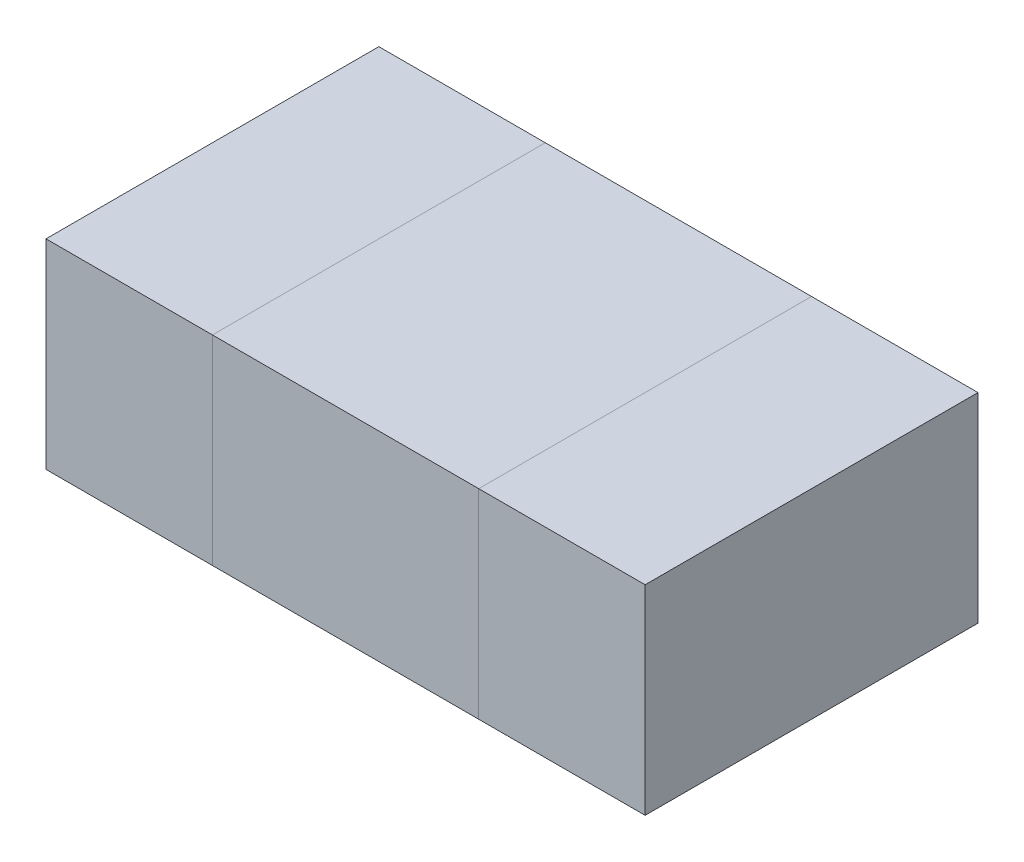
from build123d import *

# Parameters (mm, degrees)
SKETCH1_W             = 0.4
SKETCH1_H             = 0.5
BOSS_EXTRUDE1_DEPTH   = 0.3
SKETCH2_W             = 0.25
SKETCH2_H             = 0.5
BOSS_EXTRUDE2_DEPTH   = 0.3
BOSS_EXTRUDE2_2_DEPTH = 0.3


with BuildPart() as part:
    # Sketch1 → Boss-Extrude1 (new body)
    with BuildSketch(Plane(origin=(0, 0, 0), x_dir=(1, 0, 0), z_dir=(0, 1, 0))):
        Rectangle(SKETCH1_W, SKETCH1_H)
    extrude(amount=BOSS_EXTRUDE1_DEPTH)


with BuildPart() as body_2:
    # Sketch2 → Boss-Extrude2 (new body)
    with BuildSketch(Plane(origin=(0, 0, 0), x_dir=(1, 0, 0), z_dir=(0, 1, 0))):
        with Locations((-0.325, 0)):
            Rectangle(SKETCH2_W, SKETCH2_H)
    extrude(amount=BOSS_EXTRUDE2_DEPTH)


with BuildPart() as body_3:
    # Sketch2 → Boss-Extrude2 2 (new body)
    with BuildSketch(Plane(origin=(0, 0, 0), x_dir=(1, 0, 0), z_dir=(0, 1, 0))):
        with Locations((0.325, 0)):
            Rectangle(SKETCH2_W, SKETCH2_H)
    extrude(amount=BOSS_EXTRUDE2_2_DEPTH)


solid = Compound([part.part, body_2.part, body_3.part])
